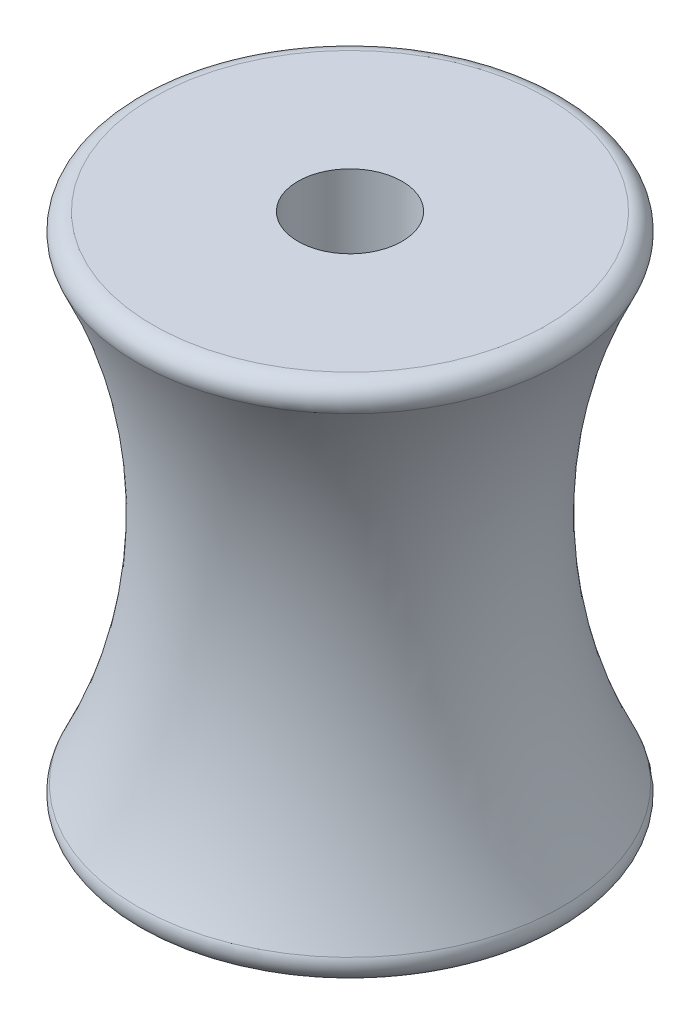
from build123d import *

# Parameters (mm, degrees)
CONG_1_R = 1


with BuildPart() as part:
    # Esquisse1 → Révolution1 (revolve)
    with BuildSketch(Plane.XY):
        with BuildLine():
            Line((-3, 30), (-3, 0))
            Line((-3, 0), (-13, 0))
            ThreePointArc((-13, 0), (-9.113109577, 15), (-13, 30))
            Line((-13, 30), (-3, 30))
        make_face()
    revolve(axis=Axis((0, 0, 0), (0, 1, 0)))

    # Congé1
    cong_1_edges = [part.edges().sort_by_distance(p)[0] for p in [
        (13, 30, 0),
        (13, 0, 0),
    ]]
    fillet(cong_1_edges, radius=CONG_1_R)


solid = part.part
